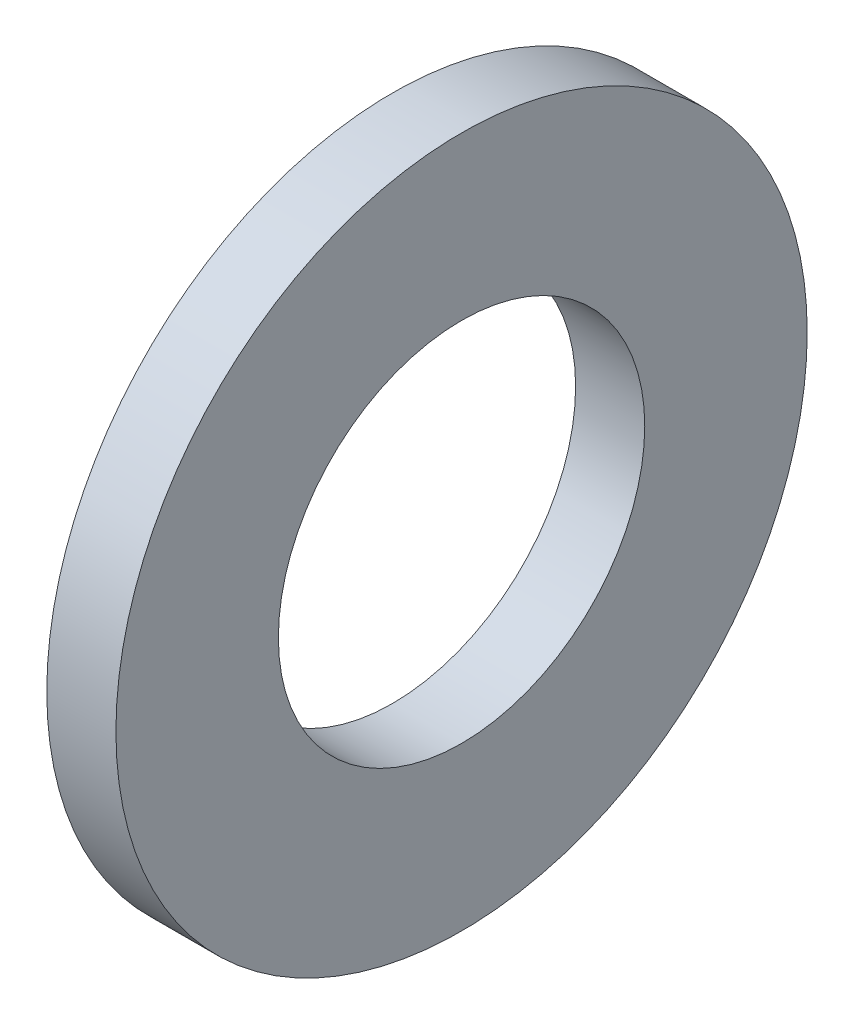
from build123d import *

# Parameters (mm, degrees)
SKETCH1_W = 1
SKETCH1_H = 2.35


with BuildPart() as part:
    # Sketch1 → Base-Revolve (revolve)
    with BuildSketch(Plane.XY):
        with Locations((-0.5, 3.825)):
            Rectangle(SKETCH1_W, SKETCH1_H)
    revolve(axis=Axis((-34.925, 0, 0), (1, 0, 0)))


solid = part.part
